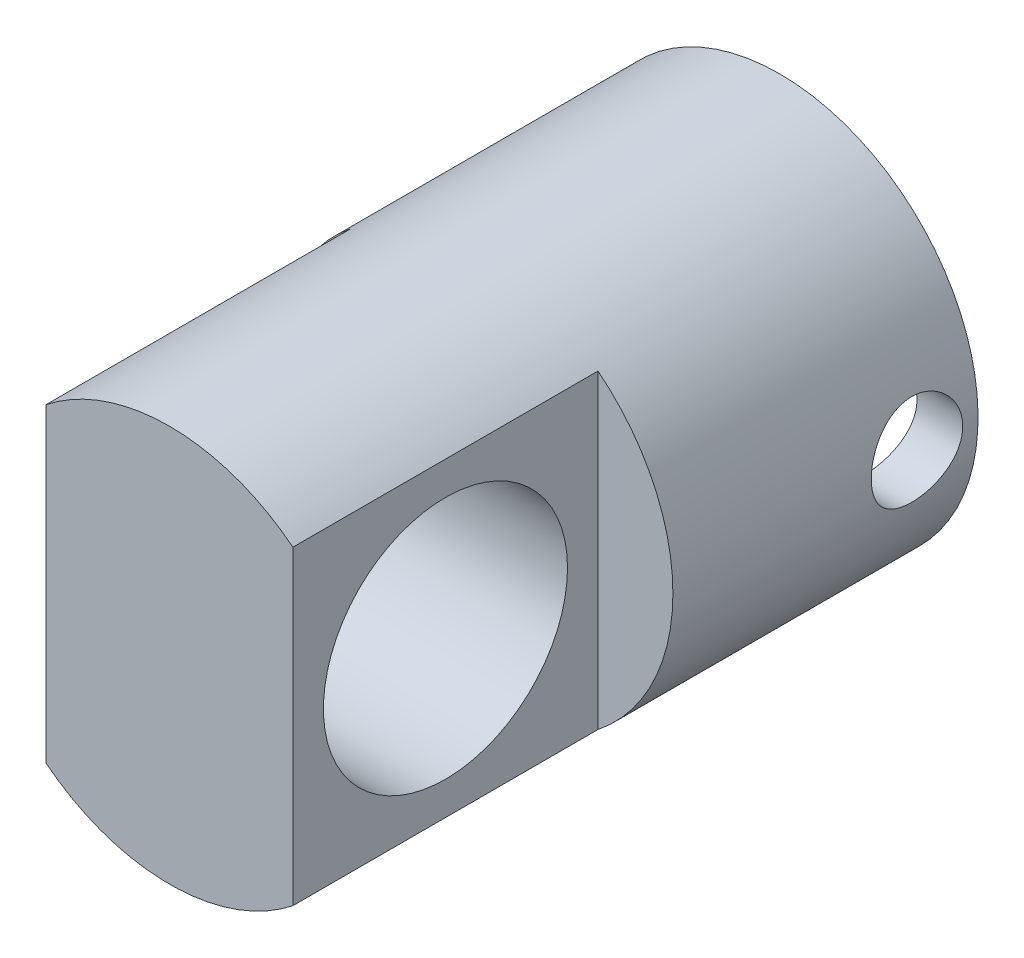
from build123d import *

# Parameters (mm, degrees)
CUT_EXTRUDE1_DEPTH      = 20
SKETCH6_R               = 8
CUT_EXTRUDE2_DEPTH      = 30
SKETCH7_R               = 3
CUT_EXTRUDE3_DEPTH      = 30
CUT_EXTRUDE3_DEPTH_BACK = 30


with BuildPart() as part:
    # Sketch2 → Revolve1 (revolve)
    with BuildSketch(Plane(origin=(0, 0, 0), x_dir=(0, 0, -1), z_dir=(1, 0, 0))):
        Polygon((0, 13), (0, 0), (40, 0), (40, 3), (25, 3), (25, 13), align=None)
    revolve(axis=Axis((0, 13, -25), (0, 0, 1)))

    # Sketch5 → Cut-Extrude1 (cut)
    with BuildSketch(Plane.XY):
        with BuildLine():
            ThreePointArc((13, 13), (11.708749973, 18.648466524), (8.091511681, 23.174843424))
            Line((8.091511681, 23.174843424), (8.091511681, 2.825156576))
            ThreePointArc((8.091511681, 2.825156576), (11.708749973, 7.351533476), (13, 13))
        make_face()
        with BuildLine():
            Line((-8.091511681, 2.825156576), (-8.091511681, 23.174843424))
            ThreePointArc((-8.091511681, 23.174843424), (-13, 13), (-8.091511681, 2.825156576))
        make_face()
    extrude(amount=-CUT_EXTRUDE1_DEPTH, mode=Mode.SUBTRACT)

    # Sketch6 → Cut-Extrude2 (cut)
    with BuildSketch(Plane(origin=(8.091511681, 0, 0), x_dir=(0, 0, -1), z_dir=(1, 0, 0))):
        with Locations((10, 13)):
            Circle(SKETCH6_R)
    extrude(amount=-CUT_EXTRUDE2_DEPTH, mode=Mode.SUBTRACT)

    # Sketch7 → Cut-Extrude3 (cut, two sides)
    with BuildSketch(Plane(origin=(0, 0, 0), x_dir=(0, 0, -1), z_dir=(1, 0, 0))) as cut_extrude3_sk:
        with Locations((36, 13)):
            Circle(SKETCH7_R)
    extrude(amount=CUT_EXTRUDE3_DEPTH, mode=Mode.SUBTRACT)
    extrude(cut_extrude3_sk.sketch, amount=-CUT_EXTRUDE3_DEPTH_BACK, mode=Mode.SUBTRACT)


solid = part.part
